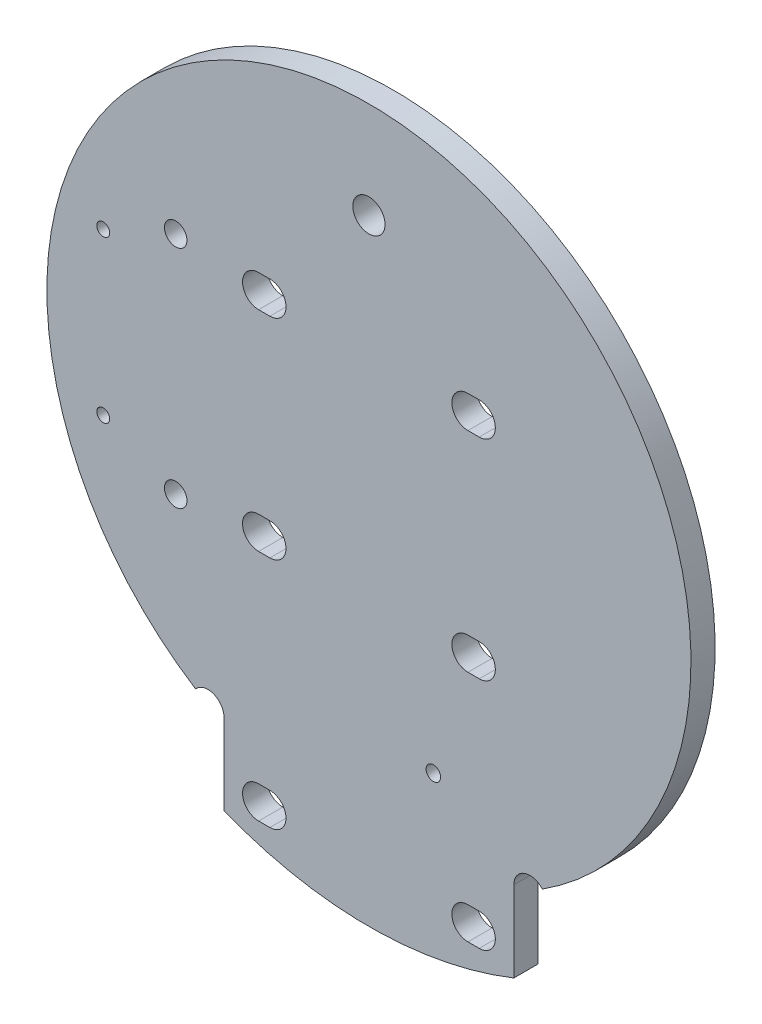
from build123d import *

# Parameters (mm, degrees)
EXTRUDE_1_DEPTH     = 1.5
SKETCH_2_R          = 0.45
SKETCH_2_R_2        = 1
SKETCH_2_R_3        = 0.4
SKETCH_2_R_4        = 0.7
CUT_EXTRUDE_1_DEPTH = 2.5


with BuildPart() as part:
    # Эскиз1 → Бобышка-Вытянуть1 (new body)
    with BuildSketch(Plane.XY):
        with BuildLine():
            Line((21, 12.5), (21, 7.481951683))
            ThreePointArc((21, 7.481951683), (30, 5.75), (39, 7.481951683))
            Line((39, 7.481951683), (39, 12.5))
            ThreePointArc((39, 12.5), (39.657111376, 13.439376065), (40.764854783, 13.144202733))
            ThreePointArc((40.764854783, 13.144202733), (30, 50), (19.235145217, 13.144202733))
            ThreePointArc((19.235145217, 13.144202733), (20.342888624, 13.439376065), (21, 12.5))
        make_face()
    extrude(amount=EXTRUDE_1_DEPTH)

    # Эскиз2 → Вырез-Вытянуть1 (cut, through all)
    with BuildSketch(Plane.XY.offset(1.5)):
        with Locations((34, 16)):
            Circle(SKETCH_2_R)
        with Locations((30, 44)):
            Circle(SKETCH_2_R_2)
        with Locations((13.5, 35)):
            Circle(SKETCH_2_R_3)
        with Locations((13.5, 25)):
            Circle(SKETCH_2_R_3)
        with Locations((18, 37)):
            Circle(SKETCH_2_R_4)
        with Locations((18, 23)):
            Circle(SKETCH_2_R_4)
        with BuildLine():
            Line((23.85, 35.5), (23.15, 35.5))
            ThreePointArc((23.15, 35.5), (22.15, 36.5), (23.15, 37.5))
            Line((23.15, 37.5), (23.85, 37.5))
            ThreePointArc((23.85, 37.5), (24.85, 36.5), (23.85, 35.5))
        make_face()
        with BuildLine():
            Line((36.85, 35.5), (36.15, 35.5))
            ThreePointArc((36.15, 35.5), (35.15, 36.5), (36.15, 37.5))
            Line((36.15, 37.5), (36.85, 37.5))
            ThreePointArc((36.85, 37.5), (37.85, 36.5), (36.85, 35.5))
        make_face()
        with BuildLine():
            Line((23.85, 22.5), (23.15, 22.5))
            ThreePointArc((23.15, 22.5), (22.15, 23.5), (23.15, 24.5))
            Line((23.15, 24.5), (23.85, 24.5))
            ThreePointArc((23.85, 24.5), (24.85, 23.5), (23.85, 22.5))
        make_face()
        with BuildLine():
            Line((36.85, 22.5), (36.15, 22.5))
            ThreePointArc((36.15, 22.5), (35.15, 23.5), (36.15, 24.5))
            Line((36.15, 24.5), (36.85, 24.5))
            ThreePointArc((36.85, 24.5), (37.85, 23.5), (36.85, 22.5))
        make_face()
        with BuildLine():
            Line((23.85, 8), (23.15, 8))
            ThreePointArc((23.15, 8), (22.15, 9), (23.15, 10))
            Line((23.15, 10), (23.85, 10))
            ThreePointArc((23.85, 10), (24.85, 9), (23.85, 8))
        make_face()
        with BuildLine():
            Line((36.85, 8), (36.15, 8))
            ThreePointArc((36.15, 8), (35.15, 9), (36.15, 10))
            Line((36.15, 10), (36.85, 10))
            ThreePointArc((36.85, 10), (37.85, 9), (36.85, 8))
        make_face()
    extrude(amount=-CUT_EXTRUDE_1_DEPTH, mode=Mode.SUBTRACT)


solid = part.part
